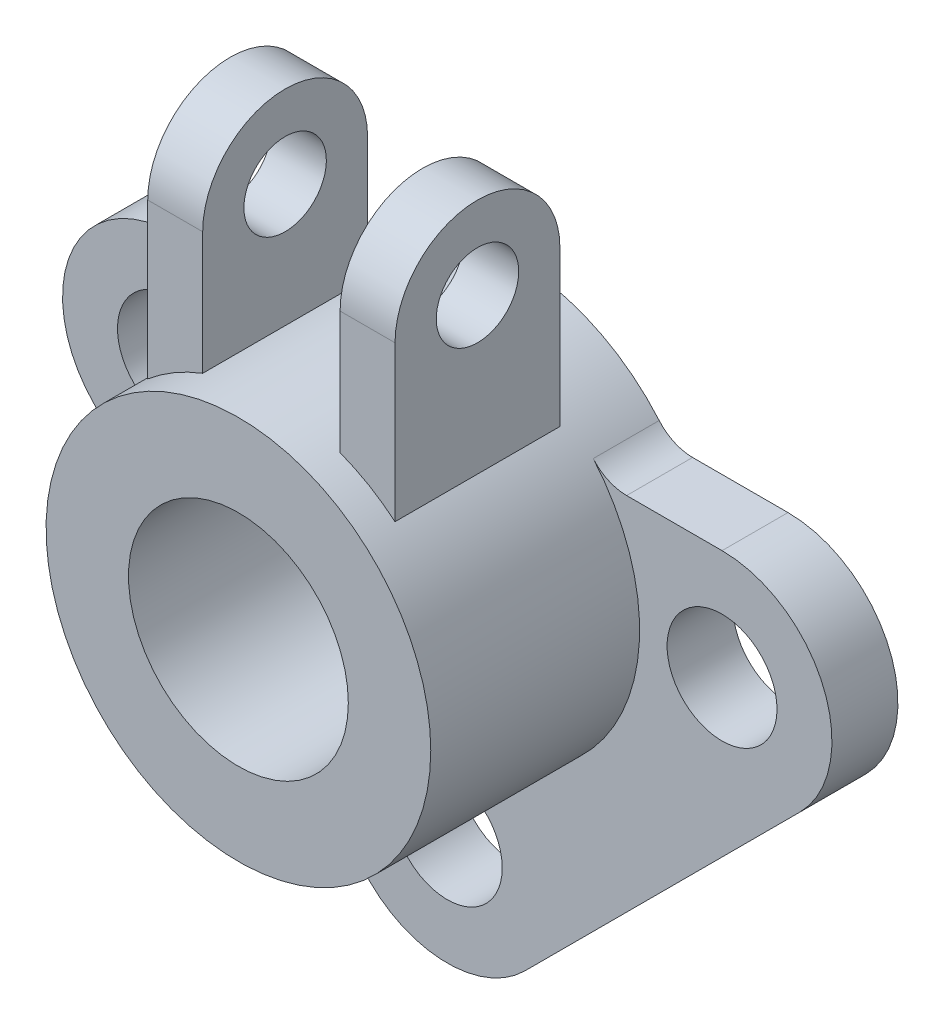
from build123d import *

# Parameters (mm, degrees)
SKETCH1_R           = 350
SKETCH1_R_2         = 200
BOSS_EXTRUDE1_DEPTH = 500
SKETCH2_R           = 100
BOSS_EXTRUDE2_DEPTH = 120
FILLET1_R           = 80
BOSS_EXTRUDE3_START = -60
BOSS_EXTRUDE3_DEPTH = 300
SKETCH4_R           = 75
CUT_EXTRUDE2_DEPTH  = 450


with BuildPart() as part:
    # Sketch1 → Boss-Extrude1 (new body)
    with BuildSketch(Plane.XY):
        Circle(SKETCH1_R)
        Circle(SKETCH1_R_2, mode=Mode.SUBTRACT)
    extrude(amount=BOSS_EXTRUDE1_DEPTH)

    # Sketch2 → Boss-Extrude2 (add)
    with BuildSketch(Plane.XY):
        with BuildLine():
            ThreePointArc((-141.421356237, -641.421356237), (0, -700), (141.421356237, -641.421356237))
            Line((141.421356237, -641.421356237), (641.421356237, -141.421356237))
            ThreePointArc((641.421356237, -141.421356237), (684.775906502, 76.536686473), (500, 200))
            Line((500, 200), (287.228132327, 200))
            ThreePointArc((287.228132327, 200), (333.938502059, 104.809717311), (350, 0))
            ThreePointArc((350, 0), (-104.809717311, -333.938502059), (-287.228132327, 200))
            Line((-287.228132327, 200), (-500, 200))
            ThreePointArc((-500, 200), (-684.775906502, 76.536686473), (-641.421356237, -141.421356237))
            Line((-641.421356237, -141.421356237), (-141.421356237, -641.421356237))
        make_face()
        with Locations((0, -500)):
            Circle(SKETCH2_R, mode=Mode.SUBTRACT)
        with Locations((-500, 0)):
            Circle(SKETCH2_R, mode=Mode.SUBTRACT)
        with Locations((500, 0)):
            Circle(SKETCH2_R, mode=Mode.SUBTRACT)
    extrude(amount=BOSS_EXTRUDE2_DEPTH)

    # Fillet1
    fillet1_edges = [part.edges().sort_by_distance(p)[0] for p in [
        (287.228132327, 200, 60),
        (-287.228132327, 200, 60),
    ]]
    fillet(fillet1_edges, radius=FILLET1_R)

    # Sketch3 → Boss-Extrude3 (add)
    with BuildSketch(Plane.XY.offset(500).offset(BOSS_EXTRUDE3_START)):
        with BuildLine():
            Line((225, 700), (125, 700))
            Line((125, 700), (125, 326.917420766))
            ThreePointArc((125, 326.917420766), (177.454262848, 301.678611434), (225, 268.095132369))
            Line((225, 268.095132369), (225, 700))
        make_face()
        with BuildLine():
            Line((-225, 700), (-225, 268.095132369))
            ThreePointArc((-225, 268.095132369), (-177.454262848, 301.678611434), (-125, 326.917420766))
            Line((-125, 326.917420766), (-125, 700))
            Line((-125, 700), (-225, 700))
        make_face()
    extrude(amount=-BOSS_EXTRUDE3_DEPTH)

    # Sketch4 → Cut-Extrude2 (cut)
    with BuildSketch(Plane(origin=(225, 0, 0), x_dir=(0, 0, -1), z_dir=(1, 0, 0))):
        with BuildLine():
            ThreePointArc((-440, 550), (-396.066017178, 656.066017178), (-290, 700))
            Line((-290, 700), (-440, 700))
            Line((-440, 700), (-440, 550))
        make_face()
        with BuildLine():
            ThreePointArc((-290, 700), (-183.933982822, 656.066017178), (-140, 550))
            Line((-140, 550), (-140, 700))
            Line((-140, 700), (-290, 700))
        make_face()
        with Locations((-290, 550)):
            Circle(SKETCH4_R)
    extrude(amount=-CUT_EXTRUDE2_DEPTH, mode=Mode.SUBTRACT)


solid = part.part
